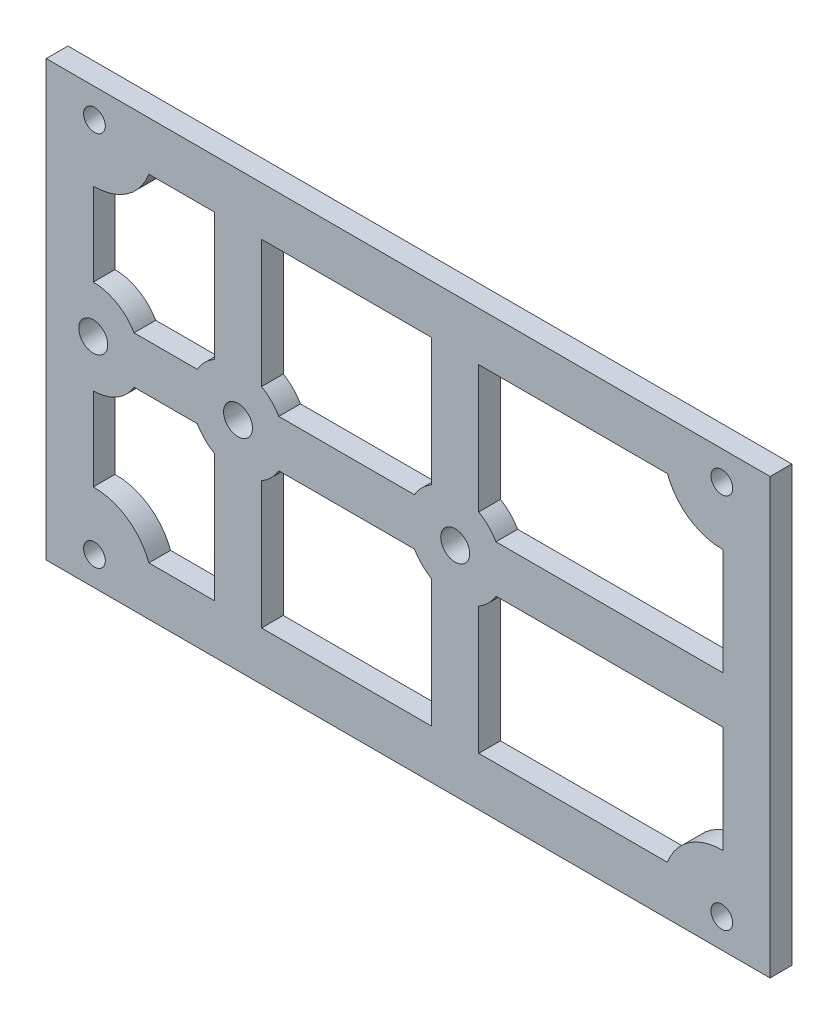
from build123d import *

# Parameters (mm, degrees)
SKETCH1_W           = 100
SKETCH1_H           = 60
BOSS_EXTRUDE1_DEPTH = 3
SKETCH3_R           = 1.5
SKETCH3_R_2         = 2
CUT_EXTRUDE2_DEPTH  = 10


with BuildPart() as part:
    # Sketch1 → Boss-Extrude1 (new body)
    with BuildSketch(Plane.XY):
        Rectangle(SKETCH1_W, SKETCH1_H)
    extrude(amount=BOSS_EXTRUDE1_DEPTH)

    # Sketch3 → Cut-Extrude2 (cut)
    with BuildSketch(Plane(origin=(0, 0, 0), x_dir=(-1, 0, 0), z_dir=(0, 0, -1))):
        with BuildLine():
            ThreePointArc((26.75, 5.629165125), (28.096194078, 4.596194078), (29.129165125, 3.25))
            Line((29.129165125, 3.25), (37.870834875, 3.25))
            ThreePointArc((37.870834875, 3.25), (40.25, 5.629165125), (43.5, 6.5))
            Line((43.5, 6.5), (43.5, 18.0017363))
            ThreePointArc((43.5, 18.0017363), (38.819316651, 19.395179534), (35.820843733, 23.25))
            Line((35.820843733, 23.25), (26.75, 23.25))
            Line((26.75, 23.25), (26.75, 5.629165125))
        make_face()
        with BuildLine():
            Line((-9.75, 5.629165125), (-9.75, 23.25))
            Line((-9.75, 23.25), (-35.820843733, 23.25))
            ThreePointArc((-35.820843733, 23.25), (-38.819316651, 19.395179534), (-43.5, 18.0017363))
            Line((-43.5, 18.0017363), (-43.5, 3.25))
            Line((-43.5, 3.25), (-12.129165125, 3.25))
            ThreePointArc((-12.129165125, 3.25), (-11.096194078, 4.596194078), (-9.75, 5.629165125))
        make_face()
        with BuildLine():
            ThreePointArc((-3.25, 5.629165125), (-1.903805922, 4.596194078), (-0.870834875, 3.25))
            Line((-0.870834875, 3.25), (17.870834875, 3.25))
            ThreePointArc((17.870834875, 3.25), (18.903805922, 4.596194078), (20.25, 5.629165125))
            Line((20.25, 5.629165125), (20.25, 23.25))
            Line((20.25, 23.25), (-3.25, 23.25))
            Line((-3.25, 23.25), (-3.25, 5.629165125))
        make_face()
        with Locations((43.333333333, 26)):
            Circle(SKETCH3_R)
        with Locations((-43.333333333, 26)):
            Circle(SKETCH3_R)
        with Locations((23.5, 0)):
            Circle(SKETCH3_R_2)
        with Locations((-6.5, 0)):
            Circle(SKETCH3_R_2)
        with Locations((43.5, 0)):
            Circle(SKETCH3_R_2)
    cut_extrude2 = extrude(amount=-CUT_EXTRUDE2_DEPTH, mode=Mode.SUBTRACT)

    # Mirror3: Cut-Extrude2 across plane
    add(cut_extrude2.mirror(Plane.ZX), mode=Mode.SUBTRACT)


solid = part.part
